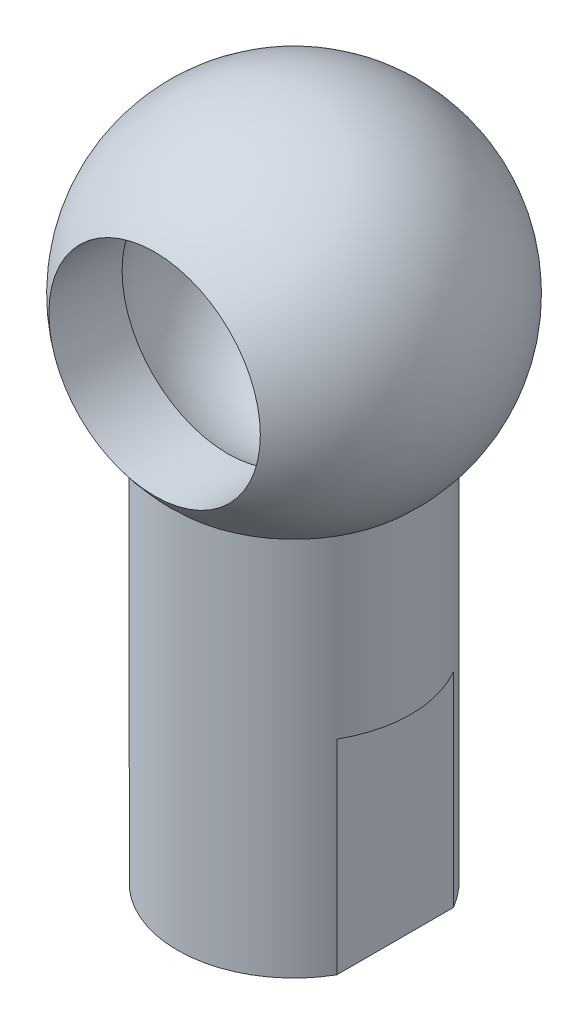
from build123d import *

# Parameters (mm, degrees)
SKETCH1_R           = 8
BOSS_EXTRUDE1_DEPTH = 35
CUT_EXTRUDE1_DEPTH  = 14
SKETCH1_4_R         = 5
CUT_EXTRUDE2_DEPTH  = 15.5
CUT_EXTRUDE3_REACH  = 26
SKETCH5_R           = 7.25


with BuildPart() as part:
    # Sketch1 → Boss-Extrude1 (new body)
    with BuildSketch(Plane(origin=(0, 0, 0), x_dir=(1, 0, 0), z_dir=(0, 1, 0))):
        Circle(SKETCH1_R)
    extrude(amount=BOSS_EXTRUDE1_DEPTH)

    # Sketch1_3 → Cut-Extrude1 (cut)
    with BuildSketch(Plane(origin=(0, 0, 0), x_dir=(1, 0, 0), z_dir=(0, 1, 0))):
        with BuildLine():
            Line((6.92820323, 4), (6.92820323, -4))
            ThreePointArc((6.92820323, -4), (7.72740661, -2.070552361), (8, 0))
            ThreePointArc((8, 0), (7.72740661, 2.070552361), (6.92820323, 4))
        make_face()
        with BuildLine():
            ThreePointArc((-6.92820323, 4), (-8, 0), (-6.92820323, -4))
            Line((-6.92820323, -4), (-6.92820323, 4))
        make_face()
    extrude(amount=CUT_EXTRUDE1_DEPTH, mode=Mode.SUBTRACT)

    # Sketch1_4 → Cut-Extrude2 (cut)
    with BuildSketch(Plane(origin=(0, 0, 0), x_dir=(1, 0, 0), z_dir=(0, 1, 0))):
        Circle(SKETCH1_4_R)
    extrude(amount=CUT_EXTRUDE2_DEPTH, mode=Mode.SUBTRACT)

    # Sketch2 one side → Revolve13 (revolve)
    with BuildSketch(Plane(origin=(0, 0, 0), x_dir=(0, 0, -1), z_dir=(1, 0, 0))):
        with BuildLine():
            Line((0, 23), (0, 47))
            ThreePointArc((0, 47), (-12, 35), (0, 23))
        make_face()
    revolve(axis=Axis((0, 35, 0), (0, 1, 0)))

    # Sketch4 one side → Cut-Revolve2 (revolve, cut)
    with BuildSketch(Plane(origin=(0, 0, 0), x_dir=(0, 0, -1), z_dir=(1, 0, 0))):
        with BuildLine():
            ThreePointArc((6.84, 35), (4.496854249, 40.656854249), (-1.16, 43))
            Line((-1.16, 43), (-1.16, 27))
            ThreePointArc((-1.16, 27), (4.496854249, 29.343145751), (6.84, 35))
        make_face()
    revolve(axis=Axis((0, 27, 1.16), (0, -1, 0)), mode=Mode.SUBTRACT)

    # Sketch5 → Cut-Extrude3 (cut, up to next)
    with BuildSketch(Plane.XY.offset(12), mode=Mode.PRIVATE) as cut_extrude3_sk1:
        with Locations((0, 35)):
            Circle(SKETCH5_R)
    cut_extrude3_tool1 = extrude(cut_extrude3_sk1.sketch, amount=-CUT_EXTRUDE3_REACH, mode=Mode.PRIVATE) & part.part
    add(cut_extrude3_tool1.solids().sort_by_distance((0, 35, 12))[0], mode=Mode.SUBTRACT)


solid = part.part
